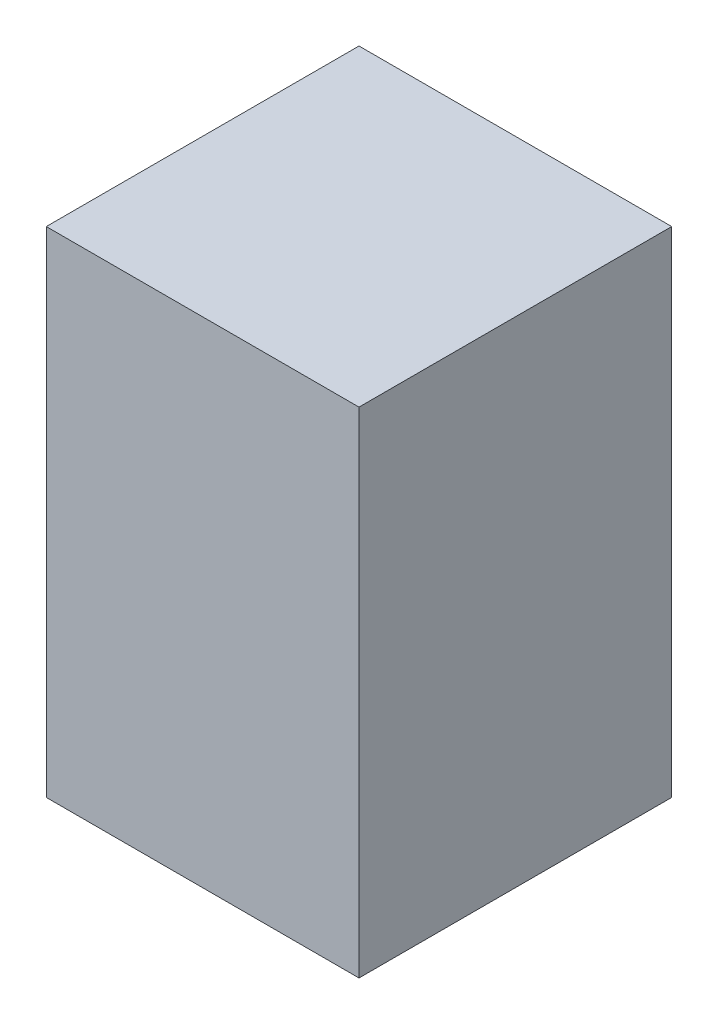
from build123d import *

# Parameters (mm, degrees)
SKETCH1_W           = 12.65
SKETCH1_H           = 12.65
BOSS_EXTRUDE1_DEPTH = 20


with BuildPart() as part:
    # Sketch1 → Boss-Extrude1 (new body)
    with BuildSketch(Plane(origin=(0, 0, 0), x_dir=(1, 0, 0), z_dir=(0, 1, 0))):
        Rectangle(SKETCH1_W, SKETCH1_H)
    extrude(amount=BOSS_EXTRUDE1_DEPTH)


solid = part.part
